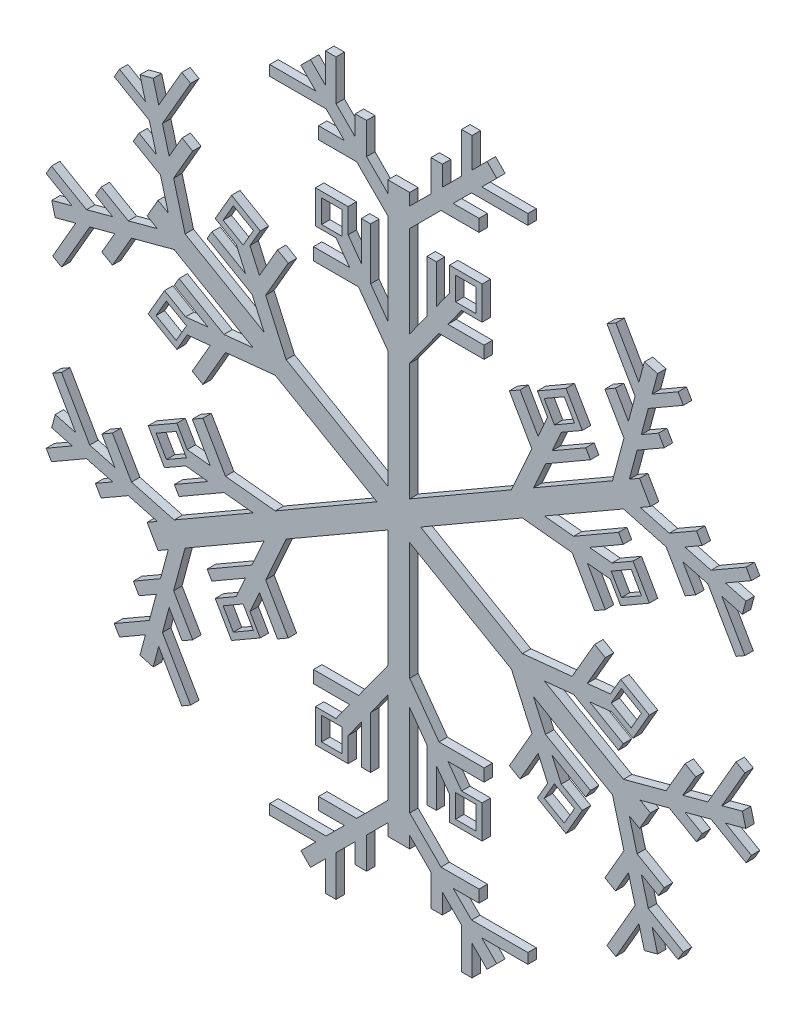
from build123d import *

# Parameters (mm, degrees)
SKETCH3_W               = 6.165626545
SKETCH3_H               = 6.967624387
BOSS_EXTRUDE2_DEPTH     = 2.54
CIRPATTERN3_COUNT       = 6
MIRROR4_COPY_1_SKETCH_W = 6.165626545
MIRROR4_COPY_1_SKETCH_H = 6.967624387
MIRROR4_COPY_1_DEPTH    = 2.54
MIRROR4_COPY_2_SKETCH_W = 6.165626545
MIRROR4_COPY_2_SKETCH_H = 6.967624387
MIRROR4_COPY_2_DEPTH    = 2.54
MIRROR4_COPY_3_SKETCH_W = 6.165626545
MIRROR4_COPY_3_SKETCH_H = 6.967624387
MIRROR4_COPY_3_DEPTH    = 2.54
MIRROR4_COPY_4_SKETCH_W = 6.165626545
MIRROR4_COPY_4_SKETCH_H = 6.967624387
MIRROR4_COPY_4_DEPTH    = 2.54
MIRROR4_COPY_5_SKETCH_W = 6.165626545
MIRROR4_COPY_5_SKETCH_H = 6.967624387
MIRROR4_COPY_5_DEPTH    = 2.54


with BuildPart() as part:
    # Sketch3 → Boss-Extrude2 (new body)
    with BuildSketch(Plane.XY):
        with BuildLine():
            Line((-3.291848542, 12.564267446), (-12.115019378, 24.769653769))
            Line((-12.115019378, 24.769653769), (-25.694606704, 24.769653769))
            Line((-25.694606704, 24.769653769), (-25.694606704, 28.491770786))
            Line((-25.694606704, 28.491770786), (-14.805706378, 28.491770786))
            Line((-14.805706378, 28.491770786), (-18.91227397, 34.172522622))
            Line((-18.91227397, 34.172522622), (-25.111041853, 34.172522622))
            Line((-25.111041853, 34.172522622), (-25.111041853, 44.152148028))
            Line((-25.111041853, 44.152148028), (-15.27517051, 44.152148028))
            Line((-15.27517051, 44.152148028), (-15.27517051, 36.801754039))
            Line((-15.27517051, 36.801754039), (-11.295510925, 31.296558279))
            Line((-11.295510925, 31.296558279), (-11.295510925, 43.041726966))
            Line((-11.295510925, 43.041726966), (-8.477915918, 43.041726966))
            Line((-8.477915918, 43.041726966), (-8.477915918, 27.398885186))
            Line((-8.477915918, 27.398885186), (-3.291848542, 20.224825317))
            Line((-3.291848542, 20.224825317), (-3.291848542, 47.71809899))
            Line((-3.291848542, 47.71809899), (-12.70185989, 57.128110337))
            Line((-12.70185989, 57.128110337), (-24.169528662, 57.128110337))
            Line((-24.169528662, 57.128110337), (-24.169528662, 60.81427154))
            Line((-24.169528662, 60.81427154), (-16.388021093, 60.81427154))
            Line((-16.388021093, 60.81427154), (-21.907814823, 66.33406527))
            Line((-21.907814823, 66.33406527), (-38.882916827, 66.33406527))
            Line((-38.882916827, 66.33406527), (-38.882916827, 69.4226744))
            Line((-38.882916827, 69.4226744), (-24.996423952, 69.4226744))
            Line((-24.996423952, 69.4226744), (-29.515305294, 73.941555742))
            Line((-29.515305294, 73.941555742), (-26.593893758, 76.862967278))
            Line((-26.593893758, 76.862967278), (-22.075012416, 72.344085936))
            Line((-22.075012416, 72.344085936), (-22.075012416, 81.38184862))
            Line((-22.075012416, 81.38184862), (-18.91227397, 81.38184862))
            Line((-18.91227397, 81.38184862), (-18.91227397, 69.181347491))
            Line((-18.91227397, 69.181347491), (-13.134487539, 63.40356106))
            Line((-13.134487539, 63.40356106), (-13.134487539, 69.4226744))
            Line((-13.134487539, 69.4226744), (-9.706936887, 69.4226744))
            Line((-9.706936887, 69.4226744), (-9.706936887, 59.976010408))
            Line((-9.706936887, 59.976010408), (-3.291848542, 53.560922063))
            Line((-3.291848542, 53.560922063), (-3.291848542, 57.128110337))
            Line((-3.291848542, 57.128110337), (0, 57.128110337))
            Line((0, 57.128110337), (0, -28.305854754))
            ThreePointArc((0, -28.305854754), (0.022561408, -28.748683437), (-0.044889168, -28.31044072))
            ThreePointArc((-0.044889168, -28.31044072), (-2.321029526, -27.554825121), (-3.291848542, -25.361817984))
            Line((-3.291848542, -25.361817984), (-3.291848542, 12.564267446))
        make_face()
        with Locations((-20.176535513, 38.970950524)):
            Rectangle(SKETCH3_W, SKETCH3_H, mode=Mode.SUBTRACT)
    boss_extrude2 = extrude(amount=BOSS_EXTRUDE2_DEPTH)

    # CirPattern3: Boss-Extrude2 ×6 about axis
    cirpattern3_axis = Axis((0, -28.527843829, 0), (0, 0, 1))
    for i in range(1, CIRPATTERN3_COUNT):
        add(boss_extrude2.rotate(cirpattern3_axis, i * 360 / CIRPATTERN3_COUNT))

    # Mirror2: Boss-Extrude2 across plane
    add(boss_extrude2.mirror(Plane(origin=(0, -28.305854754, 2.54), x_dir=(0, 0, 1), z_dir=(-1, 0, 0))))

    # Mirror4: Boss-Extrude2 across Right Plane
    add(boss_extrude2.mirror(Plane(origin=(0, 0, 0), x_dir=(0, 0, -1), z_dir=(1, 0, 0))))

    # Mirror4 copy 1 sketch → Mirror4 copy 1 (add)
    with BuildSketch(Plane(origin=(24.705837471, -14.263921915, 0), x_dir=(-0.5, 0.866025404, 0), z_dir=(0, 0, 1))):
        with BuildLine():
            Line((-3.291848542, -12.564267446), (-12.115019378, -24.769653769))
            Line((-12.115019378, -24.769653769), (-25.694606704, -24.769653769))
            Line((-25.694606704, -24.769653769), (-25.694606704, -28.491770786))
            Line((-25.694606704, -28.491770786), (-14.805706378, -28.491770786))
            Line((-14.805706378, -28.491770786), (-18.91227397, -34.172522622))
            Line((-18.91227397, -34.172522622), (-25.111041853, -34.172522622))
            Line((-25.111041853, -34.172522622), (-25.111041853, -44.152148028))
            Line((-25.111041853, -44.152148028), (-15.27517051, -44.152148028))
            Line((-15.27517051, -44.152148028), (-15.27517051, -36.801754039))
            Line((-15.27517051, -36.801754039), (-11.295510925, -31.296558279))
            Line((-11.295510925, -31.296558279), (-11.295510925, -43.041726966))
            Line((-11.295510925, -43.041726966), (-8.477915918, -43.041726966))
            Line((-8.477915918, -43.041726966), (-8.477915918, -27.398885186))
            Line((-8.477915918, -27.398885186), (-3.291848542, -20.224825317))
            Line((-3.291848542, -20.224825317), (-3.291848542, -47.71809899))
            Line((-3.291848542, -47.71809899), (-12.70185989, -57.128110337))
            Line((-12.70185989, -57.128110337), (-24.169528662, -57.128110337))
            Line((-24.169528662, -57.128110337), (-24.169528662, -60.81427154))
            Line((-24.169528662, -60.81427154), (-16.388021093, -60.81427154))
            Line((-16.388021093, -60.81427154), (-21.907814823, -66.33406527))
            Line((-21.907814823, -66.33406527), (-38.882916827, -66.33406527))
            Line((-38.882916827, -66.33406527), (-38.882916827, -69.4226744))
            Line((-38.882916827, -69.4226744), (-24.996423952, -69.4226744))
            Line((-24.996423952, -69.4226744), (-29.515305294, -73.941555742))
            Line((-29.515305294, -73.941555742), (-26.593893758, -76.862967278))
            Line((-26.593893758, -76.862967278), (-22.075012416, -72.344085936))
            Line((-22.075012416, -72.344085936), (-22.075012416, -81.38184862))
            Line((-22.075012416, -81.38184862), (-18.91227397, -81.38184862))
            Line((-18.91227397, -81.38184862), (-18.91227397, -69.181347491))
            Line((-18.91227397, -69.181347491), (-13.134487539, -63.40356106))
            Line((-13.134487539, -63.40356106), (-13.134487539, -69.4226744))
            Line((-13.134487539, -69.4226744), (-9.706936887, -69.4226744))
            Line((-9.706936887, -69.4226744), (-9.706936887, -59.976010408))
            Line((-9.706936887, -59.976010408), (-3.291848542, -53.560922063))
            Line((-3.291848542, -53.560922063), (-3.291848542, -57.128110337))
            Line((-3.291848542, -57.128110337), (0, -57.128110337))
            Line((0, -57.128110337), (0, 28.305854754))
            ThreePointArc((0, 28.305854754), (0.022561408, 28.748683437), (-0.044889168, 28.31044072))
            ThreePointArc((-0.044889168, 28.31044072), (-2.321029526, 27.554825121), (-3.291848542, 25.361817984))
            Line((-3.291848542, 25.361817984), (-3.291848542, -12.564267446))
        make_face()
        with Locations((-20.176535513, -38.970950524)):
            Rectangle(MIRROR4_COPY_1_SKETCH_W, MIRROR4_COPY_1_SKETCH_H, mode=Mode.SUBTRACT)
    extrude(amount=MIRROR4_COPY_1_DEPTH)

    # Mirror4 copy 2 sketch → Mirror4 copy 2 (add)
    with BuildSketch(Plane(origin=(24.705837471, -42.791765744, 0), x_dir=(0.5, 0.866025404, 0), z_dir=(0, 0, 1))):
        with BuildLine():
            Line((-3.291848542, -12.564267446), (-12.115019378, -24.769653769))
            Line((-12.115019378, -24.769653769), (-25.694606704, -24.769653769))
            Line((-25.694606704, -24.769653769), (-25.694606704, -28.491770786))
            Line((-25.694606704, -28.491770786), (-14.805706378, -28.491770786))
            Line((-14.805706378, -28.491770786), (-18.91227397, -34.172522622))
            Line((-18.91227397, -34.172522622), (-25.111041853, -34.172522622))
            Line((-25.111041853, -34.172522622), (-25.111041853, -44.152148028))
            Line((-25.111041853, -44.152148028), (-15.27517051, -44.152148028))
            Line((-15.27517051, -44.152148028), (-15.27517051, -36.801754039))
            Line((-15.27517051, -36.801754039), (-11.295510925, -31.296558279))
            Line((-11.295510925, -31.296558279), (-11.295510925, -43.041726966))
            Line((-11.295510925, -43.041726966), (-8.477915918, -43.041726966))
            Line((-8.477915918, -43.041726966), (-8.477915918, -27.398885186))
            Line((-8.477915918, -27.398885186), (-3.291848542, -20.224825317))
            Line((-3.291848542, -20.224825317), (-3.291848542, -47.71809899))
            Line((-3.291848542, -47.71809899), (-12.70185989, -57.128110337))
            Line((-12.70185989, -57.128110337), (-24.169528662, -57.128110337))
            Line((-24.169528662, -57.128110337), (-24.169528662, -60.81427154))
            Line((-24.169528662, -60.81427154), (-16.388021093, -60.81427154))
            Line((-16.388021093, -60.81427154), (-21.907814823, -66.33406527))
            Line((-21.907814823, -66.33406527), (-38.882916827, -66.33406527))
            Line((-38.882916827, -66.33406527), (-38.882916827, -69.4226744))
            Line((-38.882916827, -69.4226744), (-24.996423952, -69.4226744))
            Line((-24.996423952, -69.4226744), (-29.515305294, -73.941555742))
            Line((-29.515305294, -73.941555742), (-26.593893758, -76.862967278))
            Line((-26.593893758, -76.862967278), (-22.075012416, -72.344085936))
            Line((-22.075012416, -72.344085936), (-22.075012416, -81.38184862))
            Line((-22.075012416, -81.38184862), (-18.91227397, -81.38184862))
            Line((-18.91227397, -81.38184862), (-18.91227397, -69.181347491))
            Line((-18.91227397, -69.181347491), (-13.134487539, -63.40356106))
            Line((-13.134487539, -63.40356106), (-13.134487539, -69.4226744))
            Line((-13.134487539, -69.4226744), (-9.706936887, -69.4226744))
            Line((-9.706936887, -69.4226744), (-9.706936887, -59.976010408))
            Line((-9.706936887, -59.976010408), (-3.291848542, -53.560922063))
            Line((-3.291848542, -53.560922063), (-3.291848542, -57.128110337))
            Line((-3.291848542, -57.128110337), (0, -57.128110337))
            Line((0, -57.128110337), (0, 28.305854754))
            ThreePointArc((0, 28.305854754), (0.022561408, 28.748683437), (-0.044889168, 28.31044072))
            ThreePointArc((-0.044889168, 28.31044072), (-2.321029526, 27.554825121), (-3.291848542, 25.361817984))
            Line((-3.291848542, 25.361817984), (-3.291848542, -12.564267446))
        make_face()
        with Locations((-20.176535513, -38.970950524)):
            Rectangle(MIRROR4_COPY_2_SKETCH_W, MIRROR4_COPY_2_SKETCH_H, mode=Mode.SUBTRACT)
    extrude(amount=MIRROR4_COPY_2_DEPTH)

    # Mirror4 copy 3 sketch → Mirror4 copy 3 (add)
    with BuildSketch(Plane(origin=(0, -57.055687659, 0), x_dir=(1, 0, 0), z_dir=(0, 0, 1))):
        with BuildLine():
            Line((-3.291848542, -12.564267446), (-12.115019378, -24.769653769))
            Line((-12.115019378, -24.769653769), (-25.694606704, -24.769653769))
            Line((-25.694606704, -24.769653769), (-25.694606704, -28.491770786))
            Line((-25.694606704, -28.491770786), (-14.805706378, -28.491770786))
            Line((-14.805706378, -28.491770786), (-18.91227397, -34.172522622))
            Line((-18.91227397, -34.172522622), (-25.111041853, -34.172522622))
            Line((-25.111041853, -34.172522622), (-25.111041853, -44.152148028))
            Line((-25.111041853, -44.152148028), (-15.27517051, -44.152148028))
            Line((-15.27517051, -44.152148028), (-15.27517051, -36.801754039))
            Line((-15.27517051, -36.801754039), (-11.295510925, -31.296558279))
            Line((-11.295510925, -31.296558279), (-11.295510925, -43.041726966))
            Line((-11.295510925, -43.041726966), (-8.477915918, -43.041726966))
            Line((-8.477915918, -43.041726966), (-8.477915918, -27.398885186))
            Line((-8.477915918, -27.398885186), (-3.291848542, -20.224825317))
            Line((-3.291848542, -20.224825317), (-3.291848542, -47.71809899))
            Line((-3.291848542, -47.71809899), (-12.70185989, -57.128110337))
            Line((-12.70185989, -57.128110337), (-24.169528662, -57.128110337))
            Line((-24.169528662, -57.128110337), (-24.169528662, -60.81427154))
            Line((-24.169528662, -60.81427154), (-16.388021093, -60.81427154))
            Line((-16.388021093, -60.81427154), (-21.907814823, -66.33406527))
            Line((-21.907814823, -66.33406527), (-38.882916827, -66.33406527))
            Line((-38.882916827, -66.33406527), (-38.882916827, -69.4226744))
            Line((-38.882916827, -69.4226744), (-24.996423952, -69.4226744))
            Line((-24.996423952, -69.4226744), (-29.515305294, -73.941555742))
            Line((-29.515305294, -73.941555742), (-26.593893758, -76.862967278))
            Line((-26.593893758, -76.862967278), (-22.075012416, -72.344085936))
            Line((-22.075012416, -72.344085936), (-22.075012416, -81.38184862))
            Line((-22.075012416, -81.38184862), (-18.91227397, -81.38184862))
            Line((-18.91227397, -81.38184862), (-18.91227397, -69.181347491))
            Line((-18.91227397, -69.181347491), (-13.134487539, -63.40356106))
            Line((-13.134487539, -63.40356106), (-13.134487539, -69.4226744))
            Line((-13.134487539, -69.4226744), (-9.706936887, -69.4226744))
            Line((-9.706936887, -69.4226744), (-9.706936887, -59.976010408))
            Line((-9.706936887, -59.976010408), (-3.291848542, -53.560922063))
            Line((-3.291848542, -53.560922063), (-3.291848542, -57.128110337))
            Line((-3.291848542, -57.128110337), (0, -57.128110337))
            Line((0, -57.128110337), (0, 28.305854754))
            ThreePointArc((0, 28.305854754), (0.022561408, 28.748683437), (-0.044889168, 28.31044072))
            ThreePointArc((-0.044889168, 28.31044072), (-2.321029526, 27.554825121), (-3.291848542, 25.361817984))
            Line((-3.291848542, 25.361817984), (-3.291848542, -12.564267446))
        make_face()
        with Locations((-20.176535513, -38.970950524)):
            Rectangle(MIRROR4_COPY_3_SKETCH_W, MIRROR4_COPY_3_SKETCH_H, mode=Mode.SUBTRACT)
    extrude(amount=MIRROR4_COPY_3_DEPTH)

    # Mirror4 copy 4 sketch → Mirror4 copy 4 (add)
    with BuildSketch(Plane(origin=(-24.705837471, -42.791765744, 0), x_dir=(0.5, -0.866025404, 0), z_dir=(0, 0, 1))):
        with BuildLine():
            Line((-3.291848542, -12.564267446), (-12.115019378, -24.769653769))
            Line((-12.115019378, -24.769653769), (-25.694606704, -24.769653769))
            Line((-25.694606704, -24.769653769), (-25.694606704, -28.491770786))
            Line((-25.694606704, -28.491770786), (-14.805706378, -28.491770786))
            Line((-14.805706378, -28.491770786), (-18.91227397, -34.172522622))
            Line((-18.91227397, -34.172522622), (-25.111041853, -34.172522622))
            Line((-25.111041853, -34.172522622), (-25.111041853, -44.152148028))
            Line((-25.111041853, -44.152148028), (-15.27517051, -44.152148028))
            Line((-15.27517051, -44.152148028), (-15.27517051, -36.801754039))
            Line((-15.27517051, -36.801754039), (-11.295510925, -31.296558279))
            Line((-11.295510925, -31.296558279), (-11.295510925, -43.041726966))
            Line((-11.295510925, -43.041726966), (-8.477915918, -43.041726966))
            Line((-8.477915918, -43.041726966), (-8.477915918, -27.398885186))
            Line((-8.477915918, -27.398885186), (-3.291848542, -20.224825317))
            Line((-3.291848542, -20.224825317), (-3.291848542, -47.71809899))
            Line((-3.291848542, -47.71809899), (-12.70185989, -57.128110337))
            Line((-12.70185989, -57.128110337), (-24.169528662, -57.128110337))
            Line((-24.169528662, -57.128110337), (-24.169528662, -60.81427154))
            Line((-24.169528662, -60.81427154), (-16.388021093, -60.81427154))
            Line((-16.388021093, -60.81427154), (-21.907814823, -66.33406527))
            Line((-21.907814823, -66.33406527), (-38.882916827, -66.33406527))
            Line((-38.882916827, -66.33406527), (-38.882916827, -69.4226744))
            Line((-38.882916827, -69.4226744), (-24.996423952, -69.4226744))
            Line((-24.996423952, -69.4226744), (-29.515305294, -73.941555742))
            Line((-29.515305294, -73.941555742), (-26.593893758, -76.862967278))
            Line((-26.593893758, -76.862967278), (-22.075012416, -72.344085936))
            Line((-22.075012416, -72.344085936), (-22.075012416, -81.38184862))
            Line((-22.075012416, -81.38184862), (-18.91227397, -81.38184862))
            Line((-18.91227397, -81.38184862), (-18.91227397, -69.181347491))
            Line((-18.91227397, -69.181347491), (-13.134487539, -63.40356106))
            Line((-13.134487539, -63.40356106), (-13.134487539, -69.4226744))
            Line((-13.134487539, -69.4226744), (-9.706936887, -69.4226744))
            Line((-9.706936887, -69.4226744), (-9.706936887, -59.976010408))
            Line((-9.706936887, -59.976010408), (-3.291848542, -53.560922063))
            Line((-3.291848542, -53.560922063), (-3.291848542, -57.128110337))
            Line((-3.291848542, -57.128110337), (0, -57.128110337))
            Line((0, -57.128110337), (0, 28.305854754))
            ThreePointArc((0, 28.305854754), (0.022561408, 28.748683437), (-0.044889168, 28.31044072))
            ThreePointArc((-0.044889168, 28.31044072), (-2.321029526, 27.554825121), (-3.291848542, 25.361817984))
            Line((-3.291848542, 25.361817984), (-3.291848542, -12.564267446))
        make_face()
        with Locations((-20.176535513, -38.970950524)):
            Rectangle(MIRROR4_COPY_4_SKETCH_W, MIRROR4_COPY_4_SKETCH_H, mode=Mode.SUBTRACT)
    extrude(amount=MIRROR4_COPY_4_DEPTH)

    # Mirror4 copy 5 sketch → Mirror4 copy 5 (add)
    with BuildSketch(Plane(origin=(-24.705837471, -14.263921915, 0), x_dir=(-0.5, -0.866025404, 0), z_dir=(0, 0, 1))):
        with BuildLine():
            Line((-3.291848542, -12.564267446), (-12.115019378, -24.769653769))
            Line((-12.115019378, -24.769653769), (-25.694606704, -24.769653769))
            Line((-25.694606704, -24.769653769), (-25.694606704, -28.491770786))
            Line((-25.694606704, -28.491770786), (-14.805706378, -28.491770786))
            Line((-14.805706378, -28.491770786), (-18.91227397, -34.172522622))
            Line((-18.91227397, -34.172522622), (-25.111041853, -34.172522622))
            Line((-25.111041853, -34.172522622), (-25.111041853, -44.152148028))
            Line((-25.111041853, -44.152148028), (-15.27517051, -44.152148028))
            Line((-15.27517051, -44.152148028), (-15.27517051, -36.801754039))
            Line((-15.27517051, -36.801754039), (-11.295510925, -31.296558279))
            Line((-11.295510925, -31.296558279), (-11.295510925, -43.041726966))
            Line((-11.295510925, -43.041726966), (-8.477915918, -43.041726966))
            Line((-8.477915918, -43.041726966), (-8.477915918, -27.398885186))
            Line((-8.477915918, -27.398885186), (-3.291848542, -20.224825317))
            Line((-3.291848542, -20.224825317), (-3.291848542, -47.71809899))
            Line((-3.291848542, -47.71809899), (-12.70185989, -57.128110337))
            Line((-12.70185989, -57.128110337), (-24.169528662, -57.128110337))
            Line((-24.169528662, -57.128110337), (-24.169528662, -60.81427154))
            Line((-24.169528662, -60.81427154), (-16.388021093, -60.81427154))
            Line((-16.388021093, -60.81427154), (-21.907814823, -66.33406527))
            Line((-21.907814823, -66.33406527), (-38.882916827, -66.33406527))
            Line((-38.882916827, -66.33406527), (-38.882916827, -69.4226744))
            Line((-38.882916827, -69.4226744), (-24.996423952, -69.4226744))
            Line((-24.996423952, -69.4226744), (-29.515305294, -73.941555742))
            Line((-29.515305294, -73.941555742), (-26.593893758, -76.862967278))
            Line((-26.593893758, -76.862967278), (-22.075012416, -72.344085936))
            Line((-22.075012416, -72.344085936), (-22.075012416, -81.38184862))
            Line((-22.075012416, -81.38184862), (-18.91227397, -81.38184862))
            Line((-18.91227397, -81.38184862), (-18.91227397, -69.181347491))
            Line((-18.91227397, -69.181347491), (-13.134487539, -63.40356106))
            Line((-13.134487539, -63.40356106), (-13.134487539, -69.4226744))
            Line((-13.134487539, -69.4226744), (-9.706936887, -69.4226744))
            Line((-9.706936887, -69.4226744), (-9.706936887, -59.976010408))
            Line((-9.706936887, -59.976010408), (-3.291848542, -53.560922063))
            Line((-3.291848542, -53.560922063), (-3.291848542, -57.128110337))
            Line((-3.291848542, -57.128110337), (0, -57.128110337))
            Line((0, -57.128110337), (0, 28.305854754))
            ThreePointArc((0, 28.305854754), (0.022561408, 28.748683437), (-0.044889168, 28.31044072))
            ThreePointArc((-0.044889168, 28.31044072), (-2.321029526, 27.554825121), (-3.291848542, 25.361817984))
            Line((-3.291848542, 25.361817984), (-3.291848542, -12.564267446))
        make_face()
        with Locations((-20.176535513, -38.970950524)):
            Rectangle(MIRROR4_COPY_5_SKETCH_W, MIRROR4_COPY_5_SKETCH_H, mode=Mode.SUBTRACT)
    extrude(amount=MIRROR4_COPY_5_DEPTH)


solid = part.part
